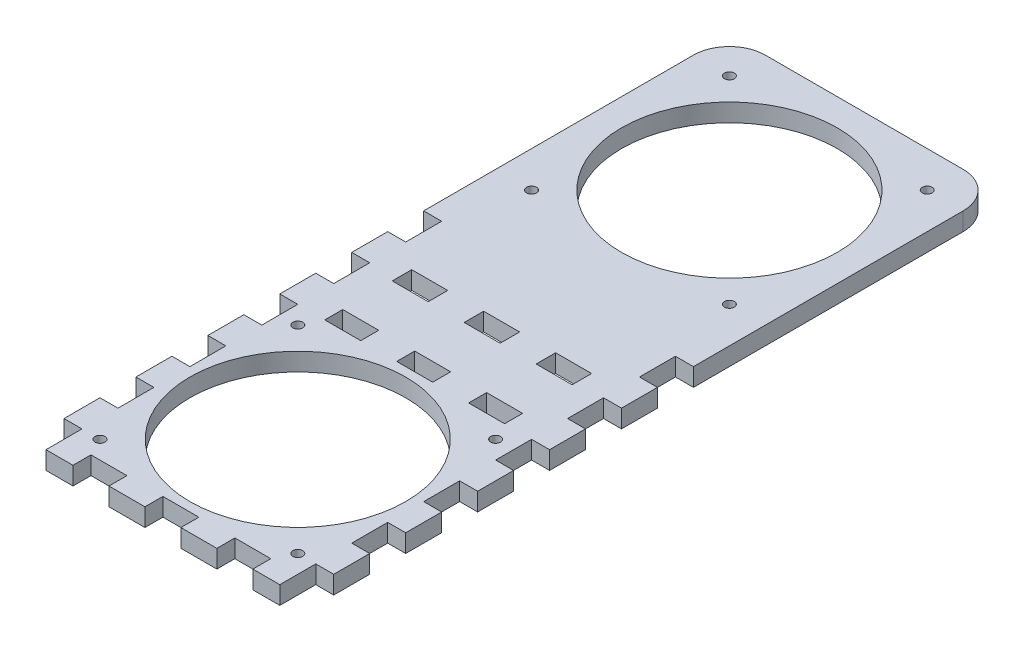
from build123d import *

# Parameters (mm, degrees)
SKETCH1_W           = 95.25
SKETCH1_H           = 247.65
BOSS_EXTRUDE1_DEPTH = 6.35
SKETCH2_R           = 38.1
CUT_EXTRUDE1_DEPTH  = 7.35
SKETCH3_W           = 6.35
SKETCH3_H           = 12.7
CUT_EXTRUDE2_DEPTH  = 7.35
LPATTERN1_COUNT     = 6
LPATTERN1_PITCH     = 25.4
SKETCH4_W           = 12.7
SKETCH4_H           = 6.35
CUT_EXTRUDE3_DEPTH  = 7.35
SKETCH5_W           = 12.7
SKETCH5_H           = 6.35
CUT_EXTRUDE4_DEPTH  = 7.35
SKETCH8_W           = 12.7
SKETCH8_H           = 6.881389346
CUT_EXTRUDE5_DEPTH  = 7.35
SKETCH9_R           = 1.75
CUT_EXTRUDE6_DEPTH  = 7.35
CIRPATTERN1_COUNT   = 4
FILLET1_R           = 12.7
SKETCH10_R          = 1.75
CUT_EXTRUDE7_DEPTH  = 7.35
CIRPATTERN2_COUNT   = 4


with BuildPart() as part:
    # Sketch1 → Boss-Extrude1 (new body)
    with BuildSketch(Plane(origin=(0, 0, 0), x_dir=(1, 0, 0), z_dir=(0, 1, 0))):
        with Locations((47.625, 123.825)):
            Rectangle(SKETCH1_W, SKETCH1_H)
    extrude(amount=BOSS_EXTRUDE1_DEPTH)

    # Sketch2 → Cut-Extrude1 (cut, through all)
    with BuildSketch(Plane(origin=(0, 6.35, 0), x_dir=(1, 0, 0), z_dir=(0, 1, 0))):
        with Locations((47.625, 200.025)):
            Circle(SKETCH2_R)
        with Locations((47.625, 47.625)):
            Circle(SKETCH2_R)
    extrude(amount=-CUT_EXTRUDE1_DEPTH, mode=Mode.SUBTRACT)

    # Sketch3 → Cut-Extrude2 (cut, through all)
    with BuildSketch(Plane(origin=(0, 6.35, 0), x_dir=(1, 0, 0), z_dir=(0, 1, 0))):
        with Locations((3.175, 6.35)):
            Rectangle(SKETCH3_W, SKETCH3_H)
        with Locations((92.075, 6.35)):
            Rectangle(SKETCH3_W, SKETCH3_H)
    cut_extrude2 = extrude(amount=-CUT_EXTRUDE2_DEPTH, mode=Mode.SUBTRACT)

    # LPattern1: Cut-Extrude2 ×6
    with Locations(*[(0, 0, -i * LPATTERN1_PITCH) for i in range(1, LPATTERN1_COUNT)]):
        add(cut_extrude2, mode=Mode.SUBTRACT)

    # Sketch4 → Cut-Extrude3 (cut, through all)
    with BuildSketch(Plane(origin=(0, 6.35, 0), x_dir=(1, 0, 0), z_dir=(0, 1, 0))):
        with Locations((47.625, 3.175)):
            Rectangle(SKETCH4_W, SKETCH4_H)
        with Locations((22.225, 3.175)):
            Rectangle(SKETCH4_W, SKETCH4_H)
        with Locations((73.025, 3.175)):
            Rectangle(SKETCH4_W, SKETCH4_H)
    extrude(amount=-CUT_EXTRUDE3_DEPTH, mode=Mode.SUBTRACT)

    # Sketch5 → Cut-Extrude4 (cut, through all)
    with BuildSketch(Plane(origin=(0, 6.35, 0), x_dir=(1, 0, 0), z_dir=(0, 1, 0))):
        with Locations((22.225, 92.075)):
            Rectangle(SKETCH5_W, SKETCH5_H)
        with Locations((47.625, 92.075)):
            Rectangle(SKETCH5_W, SKETCH5_H)
        with Locations((73.025, 92.075)):
            Rectangle(SKETCH5_W, SKETCH5_H)
    extrude(amount=-CUT_EXTRUDE4_DEPTH, mode=Mode.SUBTRACT)

    # Sketch8 → Cut-Extrude5 (cut, through all)
    with BuildSketch(Plane(origin=(0, 6.35, 0), x_dir=(1, 0, 0), z_dir=(0, 1, 0))):
        with Locations((22.225, 116.170967205)):
            Rectangle(SKETCH8_W, SKETCH8_H)
        with Locations((47.625, 116.170967205)):
            Rectangle(SKETCH8_W, SKETCH8_H)
        with Locations((73.025, 116.170967205)):
            Rectangle(SKETCH8_W, SKETCH8_H)
    extrude(amount=-CUT_EXTRUDE5_DEPTH, mode=Mode.SUBTRACT)

    # Sketch9 → Cut-Extrude6 (cut, through all)
    with BuildSketch(Plane(origin=(0, 6.35, 0), x_dir=(1, 0, 0), z_dir=(0, 1, 0))):
        with Locations((12.7, 82.55)):
            Circle(SKETCH9_R)
    cut_extrude6 = extrude(amount=-CUT_EXTRUDE6_DEPTH, mode=Mode.SUBTRACT)

    # CirPattern1: Cut-Extrude6 ×4 about axis
    cirpattern1_axis = Axis((47.625, 0, -47.625), (0, 1, 0))
    for i in range(1, CIRPATTERN1_COUNT):
        add(cut_extrude6.rotate(cirpattern1_axis, i * 360 / CIRPATTERN1_COUNT), mode=Mode.SUBTRACT)

    # Fillet1
    fillet1_edges = [part.edges().sort_by_distance(p)[0] for p in [
        (0, 3.175, -247.65),
        (95.25, 3.175, -247.65),
    ]]
    fillet(fillet1_edges, radius=FILLET1_R)

    # Sketch10 → Cut-Extrude7 (cut, through all)
    with BuildSketch(Plane(origin=(0, 6.35, 0), x_dir=(1, 0, 0), z_dir=(0, 1, 0))):
        with Locations((12.7, 234.95)):
            Circle(SKETCH10_R)
    cut_extrude7 = extrude(amount=-CUT_EXTRUDE7_DEPTH, mode=Mode.SUBTRACT)

    # CirPattern2: Cut-Extrude7 ×4 about axis
    cirpattern2_axis = Axis((47.625, 0, -200.025), (0, 1, 0))
    for i in range(1, CIRPATTERN2_COUNT):
        add(cut_extrude7.rotate(cirpattern2_axis, i * 360 / CIRPATTERN2_COUNT), mode=Mode.SUBTRACT)


solid = part.part
